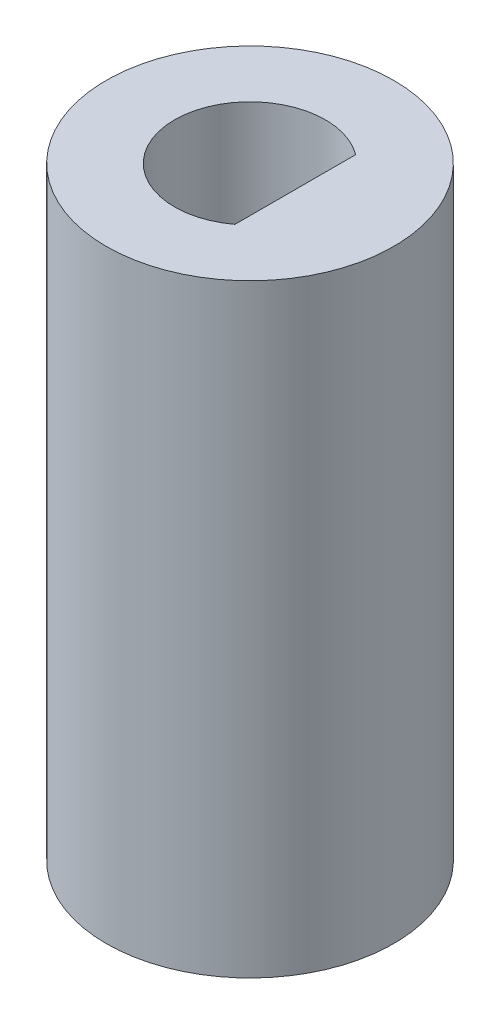
from build123d import *

# Parameters (mm, degrees)
SKETCH1_R           = 4.7625
BOSS_EXTRUDE1_DEPTH = 20
CUT_EXTRUDE1_DEPTH  = 7
SKETCH3_R           = 1.5875
CUT_EXTRUDE2_DEPTH  = 11


with BuildPart() as part:
    # Sketch1 → Boss-Extrude1 (new body)
    with BuildSketch(Plane(origin=(0, 0, 0), x_dir=(1, 0, 0), z_dir=(0, 1, 0))):
        Circle(SKETCH1_R)
    extrude(amount=BOSS_EXTRUDE1_DEPTH)

    # Sketch2 → Cut-Extrude1 (cut)
    with BuildSketch(Plane(origin=(0, 20, 0), x_dir=(1, 0, 0), z_dir=(0, 1, 0))):
        with BuildLine():
            Line((1.5, 2), (1.5, -2))
            ThreePointArc((1.5, -2), (-2.5, 0), (1.5, 2))
        make_face()
    extrude(amount=-CUT_EXTRUDE1_DEPTH, mode=Mode.SUBTRACT)

    # Sketch3 → Cut-Extrude2 (cut)
    with BuildSketch(Plane.XZ):
        Circle(SKETCH3_R)
    extrude(amount=-CUT_EXTRUDE2_DEPTH, mode=Mode.SUBTRACT)


solid = part.part
